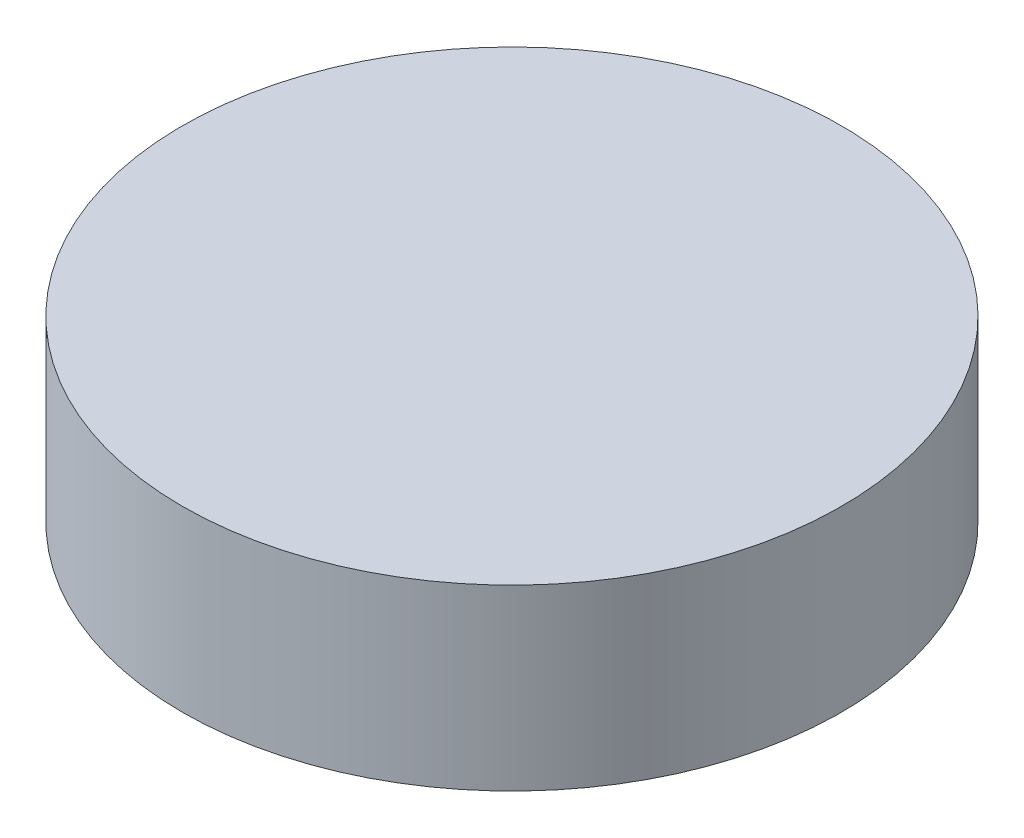
from build123d import *

# Parameters (mm, degrees)
SKETCH1_R           = 170
BOSS_EXTRUDE1_DEPTH = 92


with BuildPart() as part:
    # Sketch1 → Boss-Extrude1 (new body)
    with BuildSketch(Plane(origin=(0, 0, 0), x_dir=(1, 0, 0), z_dir=(0, 1, 0))):
        Circle(SKETCH1_R)
    extrude(amount=BOSS_EXTRUDE1_DEPTH)


solid = part.part
